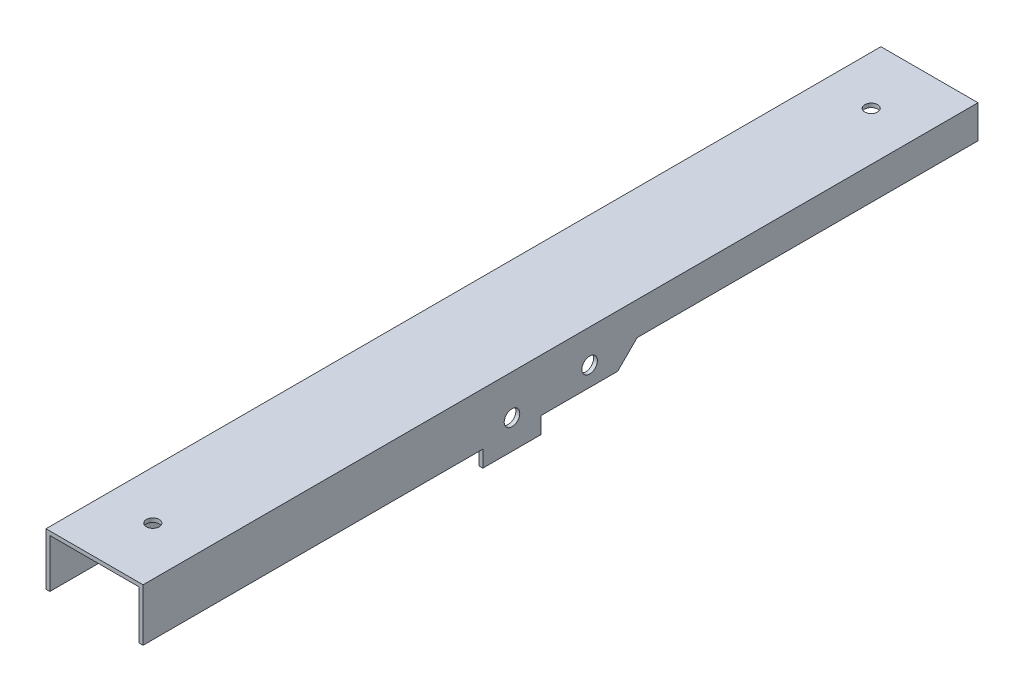
from build123d import *

# Parameters (mm, degrees)
SKETCH1_R               = 4
BOSS_EXTRUDE1_DEPTH     = 2
SKETCH2_W               = 25
SKETCH2_H               = 430
BOSS_EXTRUDE2_DEPTH     = 2
SKETCH3_R               = 3.3
CUT_EXTRUDE1_DEPTH      = 1
CUT_EXTRUDE1_DEPTH_BACK = 36.499546541


with BuildPart() as part:
    # Sketch1 → Boss-Extrude1 (new body)
    with BuildSketch(Plane.YZ):
        Polygon((15, 230), (15, -200), (0, -200), (0, -24.43744304), (-10, -14.43744304), (-10, 25), (-18.499546541, 25), (-18.499546541, 55), (-10, 55), (-10, 230), align=None)
        Circle(SKETCH1_R, mode=Mode.SUBTRACT)
        with Locations((-3.499546541, 40)):
            Circle(SKETCH1_R, mode=Mode.SUBTRACT)
    extrude(amount=-BOSS_EXTRUDE1_DEPTH)

    # Sketch2 → Boss-Extrude2 (add)
    with BuildSketch(Plane(origin=(0, 15, 0), x_dir=(-1, 0, 0), z_dir=(0, 1, 0))):
        with Locations((12.5, 15)):
            Rectangle(SKETCH2_W, SKETCH2_H)
    extrude(amount=BOSS_EXTRUDE2_DEPTH)

    # Mirror1: part across plane


with BuildPart() as part_1:
    add(part.part)
    add(part.part.mirror(Plane(origin=(-25, 17, 230), x_dir=(0, 0, 1), z_dir=(1, 0, 0))))

    # Sketch3 → Cut-Extrude1 (cut, two sides)
    with BuildSketch(Plane(origin=(0, 17, 0), x_dir=(-1, 0, 0), z_dir=(0, 1, 0))) as cut_extrude1_sk:
        with Locations((25, 200)):
            Circle(SKETCH3_R)
        with Locations((25, -170)):
            Circle(SKETCH3_R)
    extrude(amount=CUT_EXTRUDE1_DEPTH, mode=Mode.SUBTRACT)
    extrude(cut_extrude1_sk.sketch, amount=-CUT_EXTRUDE1_DEPTH_BACK, mode=Mode.SUBTRACT)


solid = part_1.part
